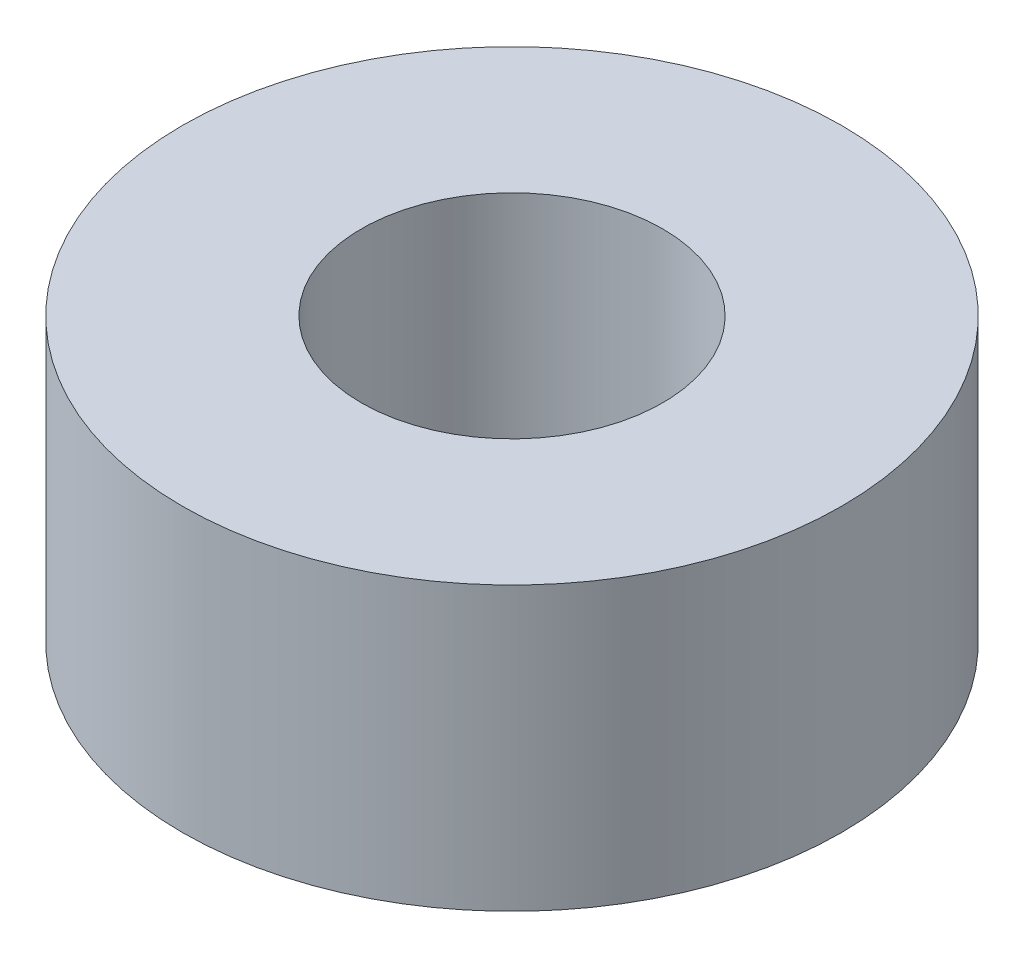
from build123d import *

# Parameters (mm, degrees)
SKETCH_1_R          = 3.5
EXTRUDE_1_DEPTH     = 3
SKETCH_2_R          = 1.6
CUT_EXTRUDE_1_DEPTH = 3


with BuildPart() as part:
    # ｽｹｯﾁ1 → ﾎﾞｽ - 押し出し1 (new body)
    with BuildSketch(Plane(origin=(0, 0, 0), x_dir=(1, 0, 0), z_dir=(0, 1, 0))):
        Circle(SKETCH_1_R)
    extrude(amount=EXTRUDE_1_DEPTH)

    # ｽｹｯﾁ2 → ｶｯﾄ - 押し出し1 (cut)
    with BuildSketch(Plane(origin=(0, 3, 0), x_dir=(1, 0, 0), z_dir=(0, 1, 0))):
        Circle(SKETCH_2_R)
    extrude(amount=-CUT_EXTRUDE_1_DEPTH, mode=Mode.SUBTRACT)


solid = part.part
